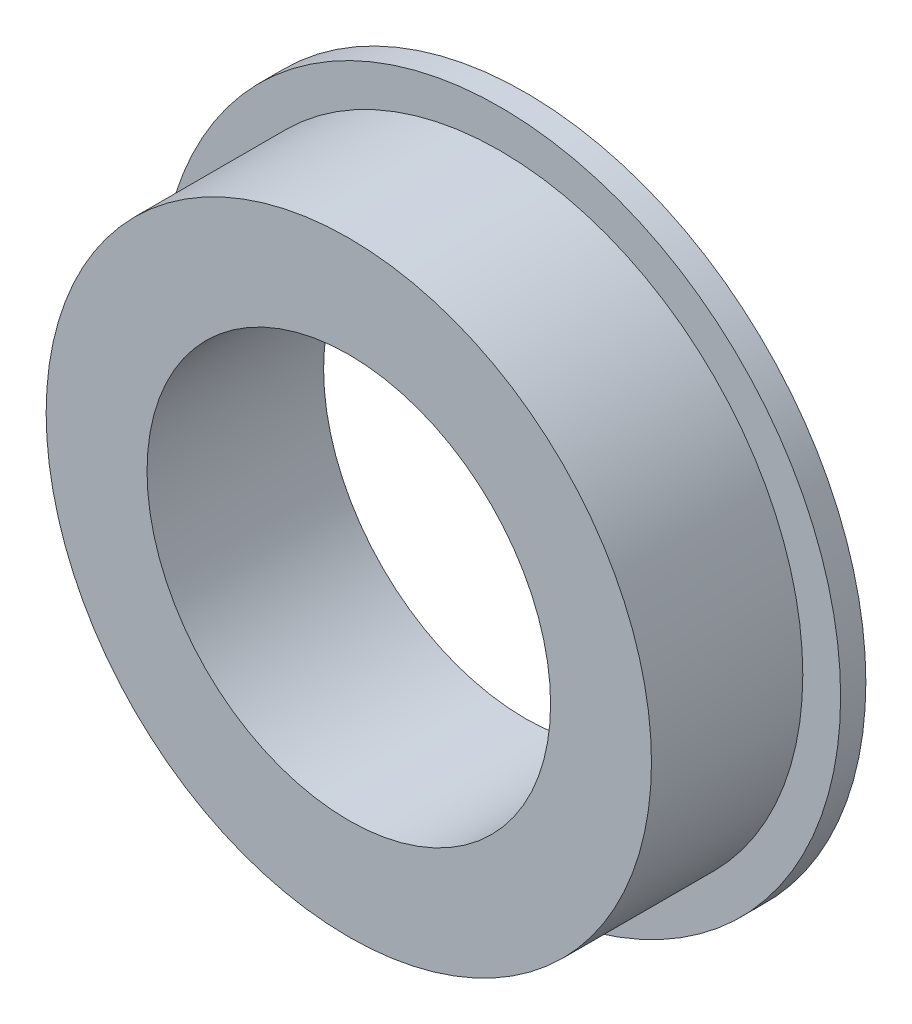
from build123d import *

# Parameters (mm, degrees)
SKETCH1_R           = 6.75
SKETCH1_R_2         = 4
BOSS_EXTRUDE1_DEPTH = 0.5
SKETCH2_R           = 6
SKETCH2_R_2         = 4
BOSS_EXTRUDE2_DEPTH = 3


with BuildPart() as part:
    # Sketch1 → Boss-Extrude1 (new body)
    with BuildSketch(Plane.XY):
        Circle(SKETCH1_R)
        Circle(SKETCH1_R_2, mode=Mode.SUBTRACT)
    extrude(amount=BOSS_EXTRUDE1_DEPTH)

    # Sketch2 → Boss-Extrude2 (add)
    with BuildSketch(Plane.XY.offset(0.5)):
        Circle(SKETCH2_R)
        Circle(SKETCH2_R_2, mode=Mode.SUBTRACT)
    extrude(amount=BOSS_EXTRUDE2_DEPTH)


solid = part.part
